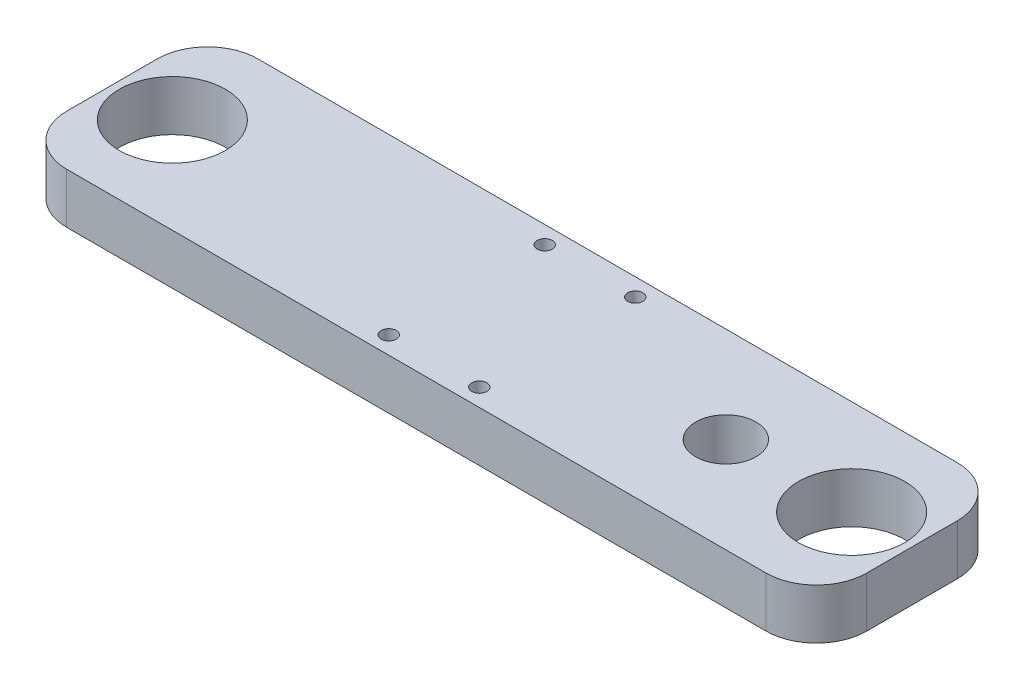
from build123d import *

# Parameters (mm, degrees)
SKETCH1_W           = 159
SKETCH1_H           = 38
SKETCH1_R           = 1.5
SKETCH1_R_2         = 10.55
SKETCH1_R_3         = 6
BOSS_EXTRUDE1_DEPTH = 10
FILLET1_R           = 10


with BuildPart() as part:
    # Sketch1 → Boss-Extrude1 (new body)
    with BuildSketch(Plane(origin=(0, 0, 0), x_dir=(1, 0, 0), z_dir=(0, 1, 0))):
        Rectangle(SKETCH1_W, SKETCH1_H)
        with Locations((9, 15.5)):
            Circle(SKETCH1_R, mode=Mode.SUBTRACT)
        with Locations((-9, 15.5)):
            Circle(SKETCH1_R, mode=Mode.SUBTRACT)
        with Locations((-9, -15.5)):
            Circle(SKETCH1_R, mode=Mode.SUBTRACT)
        with Locations((9, -15.5)):
            Circle(SKETCH1_R, mode=Mode.SUBTRACT)
        with Locations((-67.5, 0)):
            Circle(SKETCH1_R_2, mode=Mode.SUBTRACT)
        with Locations((67.5, 0)):
            Circle(SKETCH1_R_2, mode=Mode.SUBTRACT)
        with Locations((42.5, 0)):
            Circle(SKETCH1_R_3, mode=Mode.SUBTRACT)
    extrude(amount=BOSS_EXTRUDE1_DEPTH)

    # Fillet1
    fillet1_edges = [part.edges().sort_by_distance(p)[0] for p in [
        (79.5, 5, 19),
        (-79.5, 5, 19),
        (-79.5, 5, -19),
        (79.5, 5, -19),
    ]]
    fillet(fillet1_edges, radius=FILLET1_R)


solid = part.part
